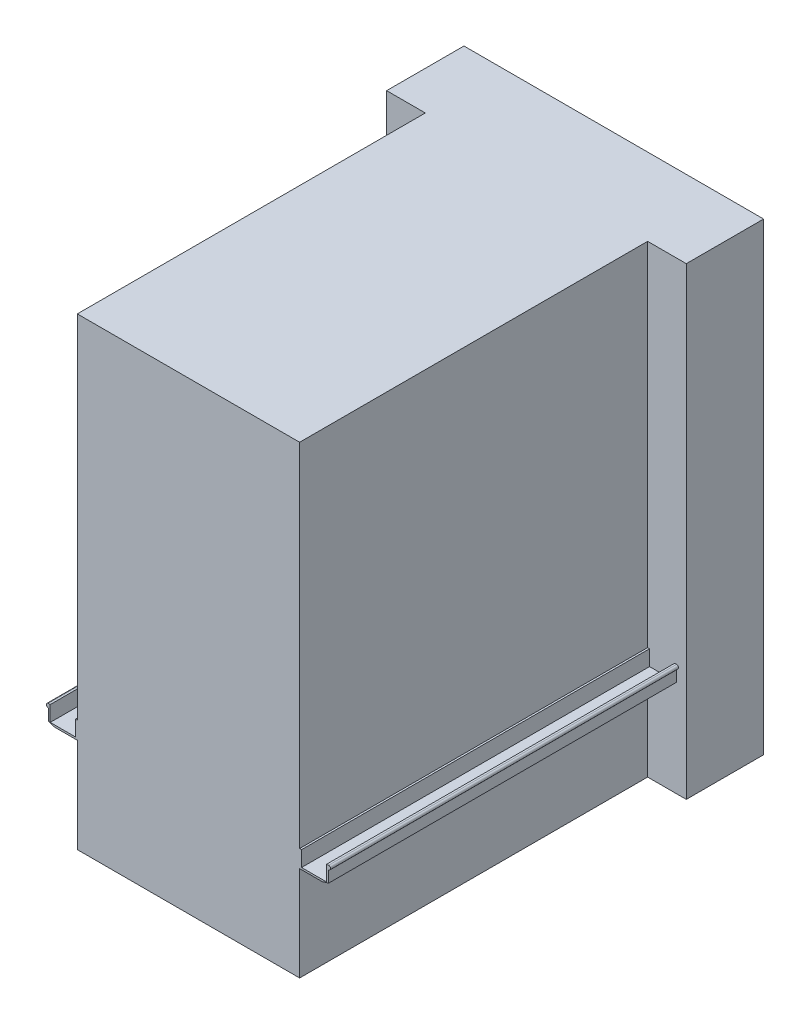
from build123d import *

# Parameters (mm, degrees)
EXTRUDE_1_DEPTH = 1800
SKETCH_2_W      = 1550
SKETCH_2_H      = 2400
EXTRUDE_2_DEPTH = 400


with BuildPart() as part:
    # 草圖1 → 填料-伸長1 (new body)
    with BuildSketch(Plane.XY):
        with BuildLine():
            ThreePointArc((-725, 329.458185741), (-735, 319.458185741), (-725, 309.458185741))
            Line((-725, 309.458185741), (-725, 249.458185741))
            Line((-725, 249.458185741), (-692.026095563, 239.458185741))
            Line((-692.026095563, 239.458185741), (-575, 239.458185741))
            Line((-575, 239.458185741), (-575, -250.541814259))
            Line((-575, -250.541814259), (0, -250.541814259))
            Line((0, -250.541814259), (0, 2149.458185741))
            Line((0, 2149.458185741), (-575, 2149.458185741))
            Line((-575, 2149.458185741), (-575, 329.458185741))
            Line((-575, 329.458185741), (-584.95081424, 329.458185741))
            Line((-584.95081424, 329.458185741), (-584.95081424, 249.408999982))
            Line((-584.95081424, 249.408999982), (-715.04918576, 249.408999982))
            Line((-715.04918576, 249.408999982), (-715.04918576, 329.458185741))
            Line((-715.04918576, 329.458185741), (-725, 329.458185741))
        make_face()
        with BuildLine():
            Line((0, 2149.458185741), (0, -250.541814259))
            Line((0, -250.541814259), (575, -250.541814259))
            Line((575, -250.541814259), (575, 239.458185741))
            Line((575, 239.458185741), (692.026095563, 239.458185741))
            Line((692.026095563, 239.458185741), (725, 249.458185741))
            Line((725, 249.458185741), (725, 309.458185741))
            ThreePointArc((725, 309.458185741), (735, 319.458185741), (725, 329.458185741))
            Line((725, 329.458185741), (715.04918576, 329.458185741))
            Line((715.04918576, 329.458185741), (715.04918576, 249.408999982))
            Line((715.04918576, 249.408999982), (584.95081424, 249.408999982))
            Line((584.95081424, 249.408999982), (584.95081424, 329.458185741))
            Line((584.95081424, 329.458185741), (575, 329.458185741))
            Line((575, 329.458185741), (575, 2149.458185741))
            Line((575, 2149.458185741), (0, 2149.458185741))
        make_face()
    extrude(amount=EXTRUDE_1_DEPTH)

    # 草圖2 → 填料-伸長2 (add)
    with BuildSketch(Plane(origin=(0, 0, 0), x_dir=(-1, 0, 0), z_dir=(0, 0, -1))):
        with Locations((0, 949.458185741)):
            Rectangle(SKETCH_2_W, SKETCH_2_H)
    extrude(amount=EXTRUDE_2_DEPTH)


solid = part.part
